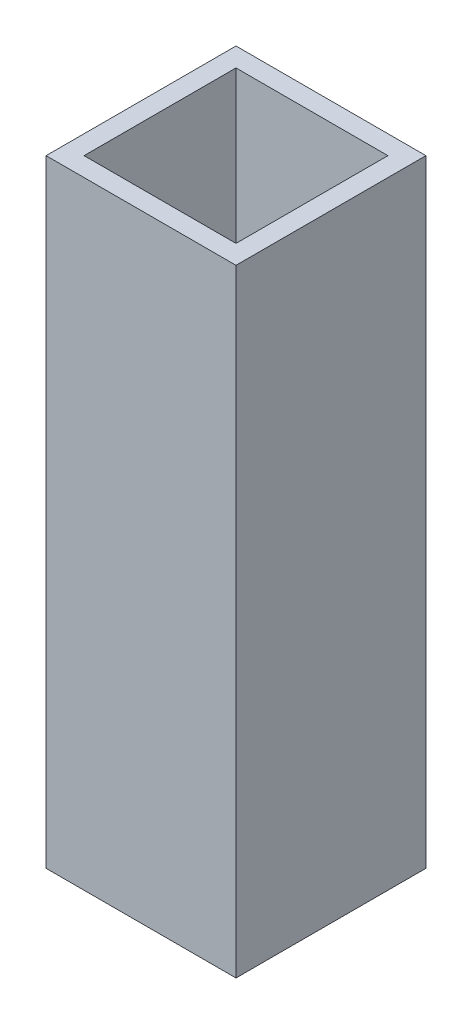
from build123d import *

# Parameters (mm, degrees)
SKETCH1_W           = 25.4
SKETCH1_H           = 25.4
SKETCH1_W_2         = 20.32
SKETCH1_H_2         = 20.32
EXTRUDE_THIN1_DEPTH = 82.55


with BuildPart() as part:
    # Sketch1 → Extrude-Thin1 (new body)
    with BuildSketch(Plane(origin=(0, 0, 0), x_dir=(1, 0, 0), z_dir=(0, 1, 0))):
        with Locations((12.7, 12.7)):
            Rectangle(SKETCH1_W, SKETCH1_H)
        with Locations((12.7, 12.7)):
            Rectangle(SKETCH1_W_2, SKETCH1_H_2, mode=Mode.SUBTRACT)
    extrude(amount=EXTRUDE_THIN1_DEPTH)


solid = part.part
